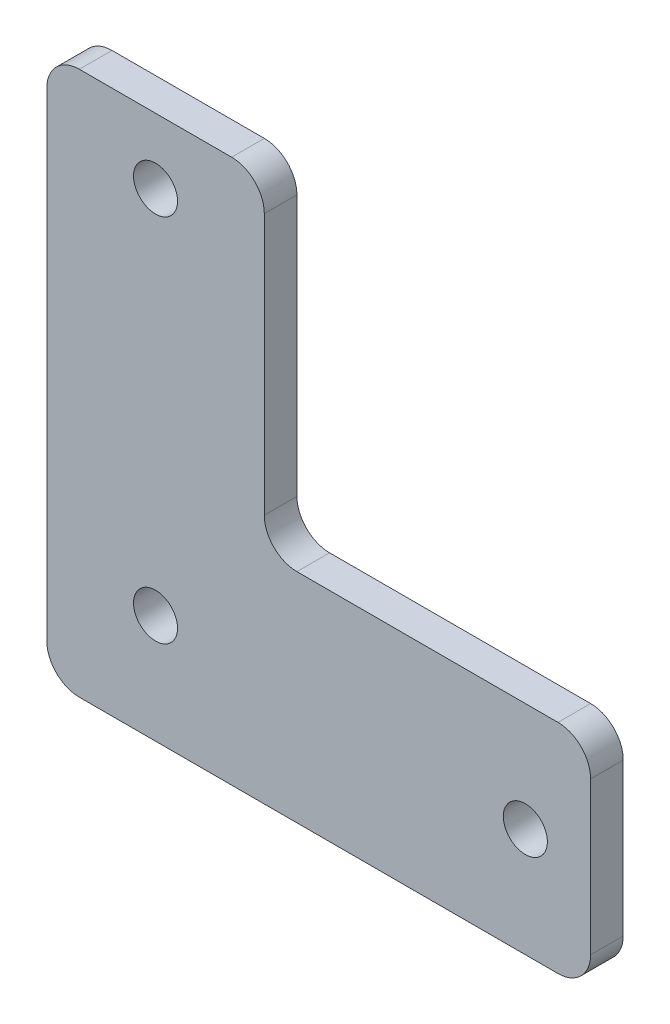
from build123d import *

# Parameters (mm, degrees)
EXTRUDE_1_DEPTH     = 3
SKETCH_2_R          = 2.025
CUT_EXTRUDE_1_DEPTH = 3
FILLET_1_R          = 3


with BuildPart() as part:
    # 草图1 → 凸台-拉伸1 (new body)
    with BuildSketch(Plane.XY):
        Polygon((0, 0), (0, 50), (20, 50), (20, 20), (50, 20), (50, 0), align=None)
    extrude(amount=EXTRUDE_1_DEPTH)

    # 草图2 → 切除-拉伸1 (cut)
    with BuildSketch(Plane.XY.offset(3)):
        with Locations((10, 10)):
            Circle(SKETCH_2_R)
        with Locations((10, 44)):
            Circle(SKETCH_2_R)
        with Locations((44, 10)):
            Circle(SKETCH_2_R)
    extrude(amount=-CUT_EXTRUDE_1_DEPTH, mode=Mode.SUBTRACT)

    # 圆角1
    fillet_1_edges = [part.edges().sort_by_distance(p)[0] for p in [
        (0, 0, 1.5),
        (0, 50, 1.5),
        (20, 50, 1.5),
        (20, 20, 1.5),
        (50, 20, 1.5),
        (50, 0, 1.5),
    ]]
    fillet(fillet_1_edges, radius=FILLET_1_R)


solid = part.part
